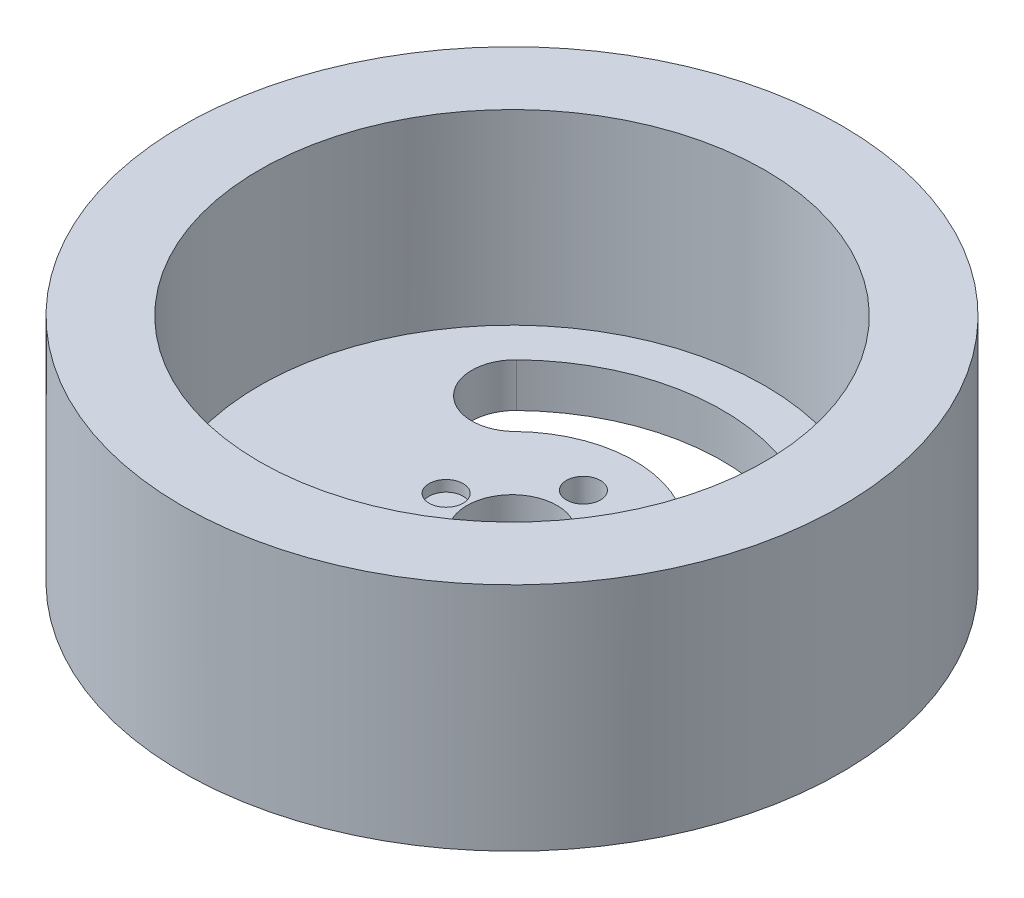
from build123d import *

# Parameters (mm, degrees)
SKETCH_1_R          = 30
SKETCH_1_R_2        = 23
EXTRUDE_1_DEPTH     = 21
SKETCH_2_R          = 23
SKETCH_2_R_2        = 4.1
SKETCH_2_R_3        = 1.55
EXTRUDE_2_DEPTH     = 1
SKETCH_3_R          = 30
SKETCH_3_R_2        = 1.55
SKETCH_3_R_3        = 4.1
EXTRUDE_3_DEPTH     = 3
SKETCH_4_R          = 30
CUT_EXTRUDE_1_DEPTH = 3


with BuildPart() as part:
    # 草图1 → 凸台-拉伸1 (new body)
    with BuildSketch(Plane(origin=(0, 0, 0), x_dir=(1, 0, 0), z_dir=(0, 1, 0))):
        Circle(SKETCH_1_R)
        Circle(SKETCH_1_R_2, mode=Mode.SUBTRACT)
    extrude(amount=EXTRUDE_1_DEPTH)

    # 草图2 → 凸台-拉伸2 (add)
    with BuildSketch(Plane.XZ):
        Circle(SKETCH_2_R)
        Circle(SKETCH_2_R_2, mode=Mode.SUBTRACT)
        with Locations((6, 0)):
            Circle(SKETCH_2_R_3, mode=Mode.SUBTRACT)
        with Locations((-6, 0)):
            Circle(SKETCH_2_R_3, mode=Mode.SUBTRACT)
        with Locations((0, 6.5)):
            Circle(SKETCH_2_R_3, mode=Mode.SUBTRACT)
        with Locations((0, -6.5)):
            Circle(SKETCH_2_R_3, mode=Mode.SUBTRACT)
        with BuildLine():
            ThreePointArc((13.744660155, 13.324975875), (0.2967616, 19.141123201), (-13.324975875, 13.744660155))
            ThreePointArc((-13.324975875, 13.744660155), (-13.412668503, 8.088485652), (-7.756494001, 8.000793024))
            ThreePointArc((-7.756494001, 8.000793024), (0.172745496, 11.142084508), (8.000793024, 7.756494001))
            ThreePointArc((8.000793024, 7.756494001), (13.656967527, 7.668801373), (13.744660155, 13.324975875))
        make_face(mode=Mode.SUBTRACT)
        with BuildLine():
            ThreePointArc((13.744660155, -13.324975875), (0.2967616, -19.141123201), (-13.324975875, -13.744660155))
            ThreePointArc((-13.324975875, -13.744660155), (-13.412668503, -8.088485652), (-7.756494001, -8.000793024))
            ThreePointArc((-7.756494001, -8.000793024), (0.172745496, -11.142084508), (8.000793024, -7.756494001))
            ThreePointArc((8.000793024, -7.756494001), (13.656967527, -7.668801373), (13.744660155, -13.324975875))
        make_face(mode=Mode.SUBTRACT)
    extrude(amount=-EXTRUDE_2_DEPTH)

    # 草图3 → 凸台-拉伸3 (add)
    with BuildSketch(Plane.XZ):
        Circle(SKETCH_3_R)
        with Locations((0, -6.5)):
            Circle(SKETCH_3_R_2, mode=Mode.SUBTRACT)
        with Locations((6, 0)):
            Circle(SKETCH_3_R_2, mode=Mode.SUBTRACT)
        Circle(SKETCH_3_R_3, mode=Mode.SUBTRACT)
        with Locations((0, 6.5)):
            Circle(SKETCH_3_R_2, mode=Mode.SUBTRACT)
        with BuildLine():
            ThreePointArc((-7.756494001, -8.000793024), (-13.412668503, -8.088485652), (-13.324975875, -13.744660155))
            ThreePointArc((-13.324975875, -13.744660155), (0.2967616, -19.141123201), (13.744660155, -13.324975875))
            ThreePointArc((13.744660155, -13.324975875), (13.656967527, -7.668801373), (8.000793024, -7.756494001))
            ThreePointArc((8.000793024, -7.756494001), (0.172745496, -11.142084508), (-7.756494001, -8.000793024))
        make_face(mode=Mode.SUBTRACT)
        with BuildLine():
            ThreePointArc((8.000793024, 7.756494001), (13.656967527, 7.668801373), (13.744660155, 13.324975875))
            ThreePointArc((13.744660155, 13.324975875), (0.2967616, 19.141123201), (-13.324975875, 13.744660155))
            ThreePointArc((-13.324975875, 13.744660155), (-13.412668503, 8.088485652), (-7.756494001, 8.000793024))
            ThreePointArc((-7.756494001, 8.000793024), (0.172745496, 11.142084508), (8.000793024, 7.756494001))
        make_face(mode=Mode.SUBTRACT)
    extrude(amount=EXTRUDE_3_DEPTH)

    # 草图4 → 切除-拉伸1 (cut)
    with BuildSketch(Plane(origin=(0, 21, 0), x_dir=(1, 0, 0), z_dir=(0, 1, 0))):
        Circle(SKETCH_4_R)
    extrude(amount=-CUT_EXTRUDE_1_DEPTH, mode=Mode.SUBTRACT)


solid = part.part
